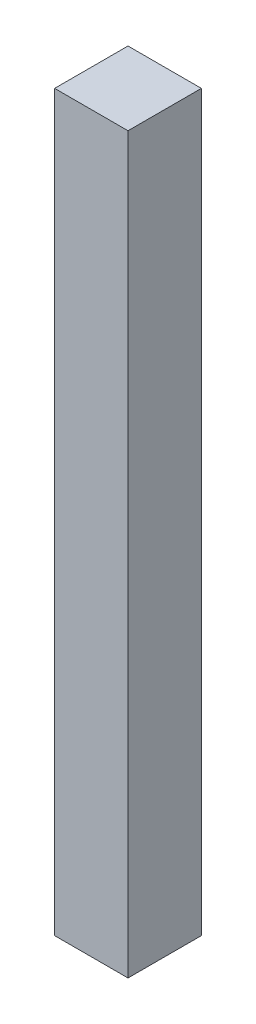
from build123d import *

# Parameters (mm, degrees)
SKETCH1_W           = 6.35
SKETCH1_H           = 6.35
BOSS_EXTRUDE1_DEPTH = 63.5


with BuildPart() as part:
    # Sketch1 → Boss-Extrude1 (new body)
    with BuildSketch(Plane(origin=(0, 0, 0), x_dir=(1, 0, 0), z_dir=(0, 1, 0))):
        Rectangle(SKETCH1_W, SKETCH1_H)
    extrude(amount=BOSS_EXTRUDE1_DEPTH)


solid = part.part
